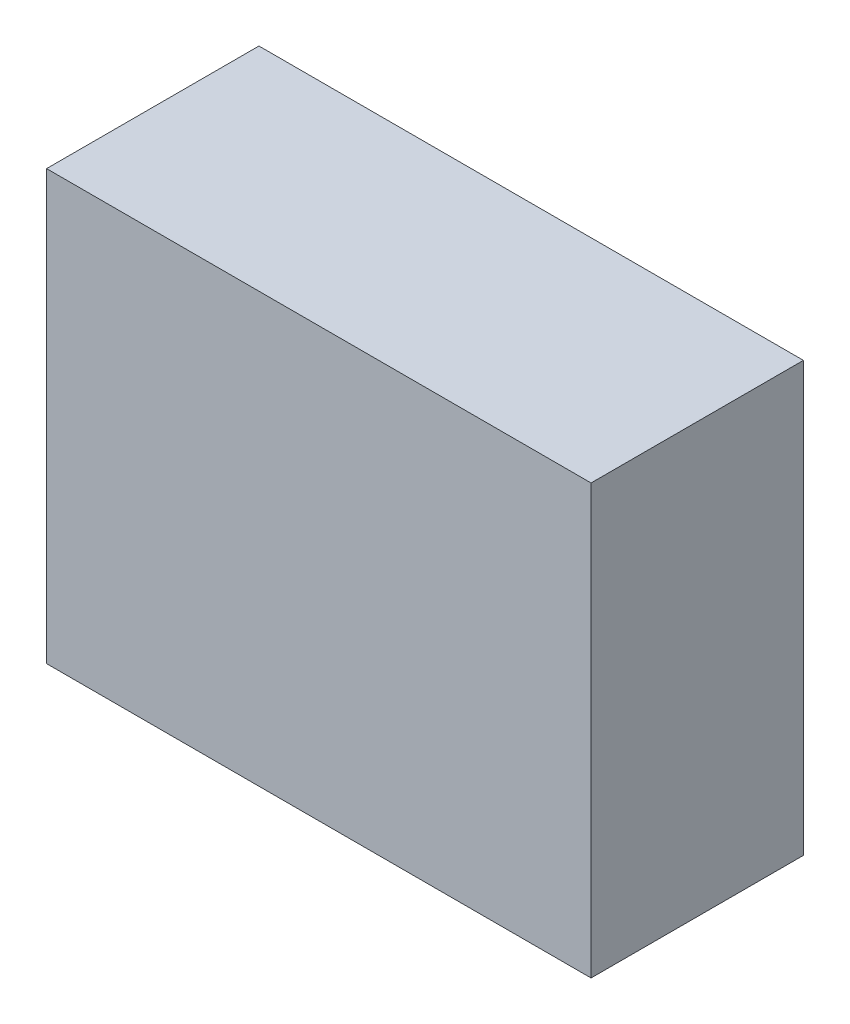
from build123d import *

# Parameters (mm, degrees)
SKETCH1_W           = 31.75
SKETCH1_H           = 25
BOSS_EXTRUDE1_DEPTH = 12.38256


with BuildPart() as part:
    # Sketch1 → Boss-Extrude1 (new body)
    with BuildSketch(Plane.XY):
        Rectangle(SKETCH1_W, SKETCH1_H)
    extrude(amount=BOSS_EXTRUDE1_DEPTH)


solid = part.part
